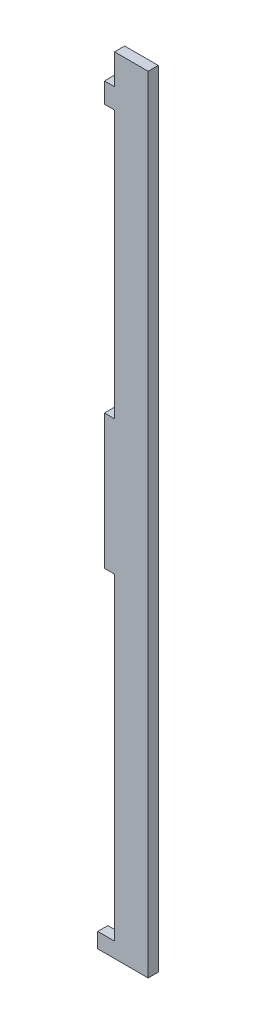
from build123d import *

# Parameters (mm, degrees)
BOSS_EXTRUDE1_DEPTH = 3


with BuildPart() as part:
    # Sketch2 → Boss-Extrude1 (new body)
    with BuildSketch(Plane.XY):
        Polygon((-10, 114.297102276), (0, 114.297102276), (0, -119.202897724), (-15, -119.202897724), (-15, -114.702897724), (-10, -114.702897724), (-10, -20.202897724), (-13, -20.202897724), (-13, 19.797102276), (-10, 19.797102276), (-10, 99.297102276), (-13, 99.297102276), (-13, 105.297102276), (-10, 105.297102276), align=None)
    extrude(amount=BOSS_EXTRUDE1_DEPTH)


solid = part.part
